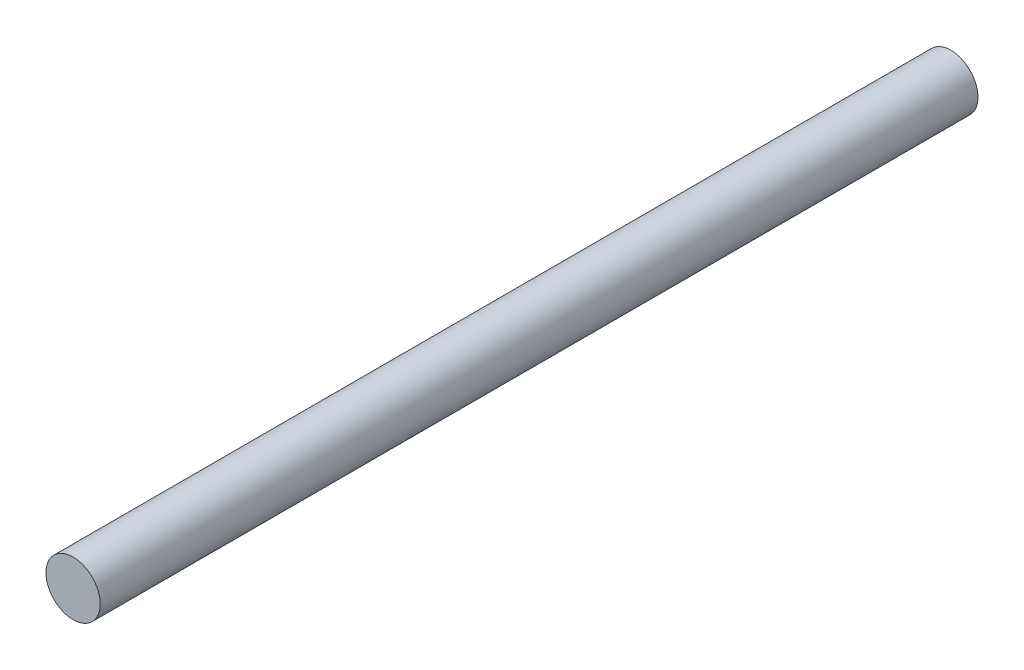
from build123d import *

# Parameters (mm, degrees)
SKETCH1_R           = 3
BOSS_EXTRUDE1_DEPTH = 97


with BuildPart() as part:
    # Sketch1 → Boss-Extrude1 (new body)
    with BuildSketch(Plane.XY):
        Circle(SKETCH1_R)
    extrude(amount=BOSS_EXTRUDE1_DEPTH)


solid = part.part
